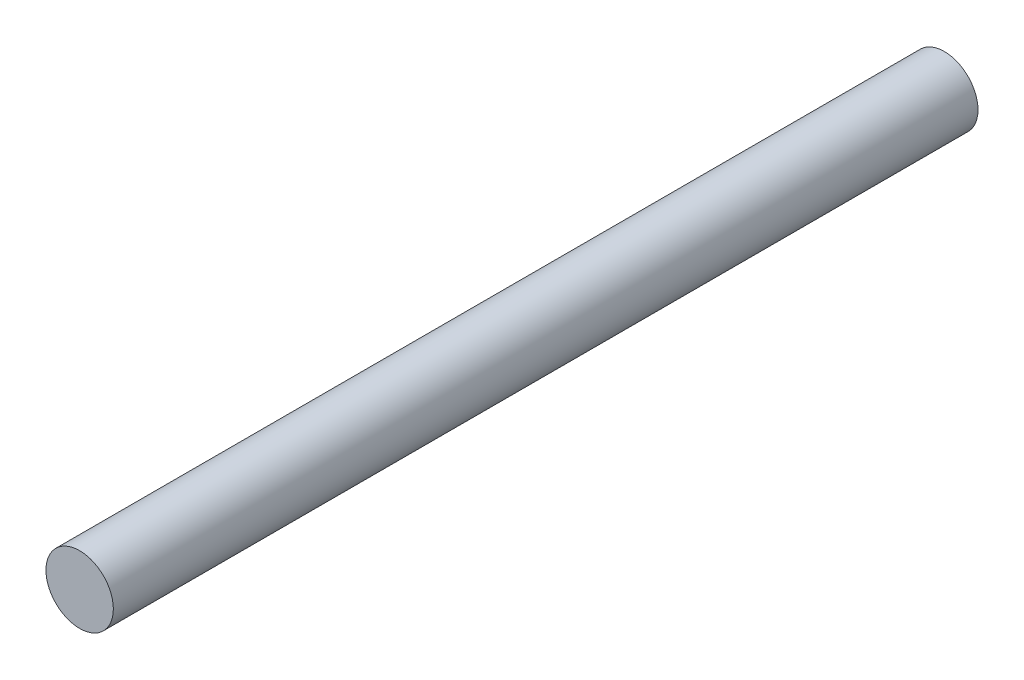
from build123d import *

# Parameters (mm, degrees)
SKETCH3_R                = 2
BOSS_EXTRUDE1_DEPTH      = 32.004
BOSS_EXTRUDE1_DEPTH_BACK = 19.304


with BuildPart() as part:
    # Sketch3 → Boss-Extrude1 (new body, two sides)
    with BuildSketch(Plane.XY) as boss_extrude1_sk:
        Circle(SKETCH3_R)
    extrude(amount=BOSS_EXTRUDE1_DEPTH)
    extrude(boss_extrude1_sk.sketch, amount=-BOSS_EXTRUDE1_DEPTH_BACK)


solid = part.part
